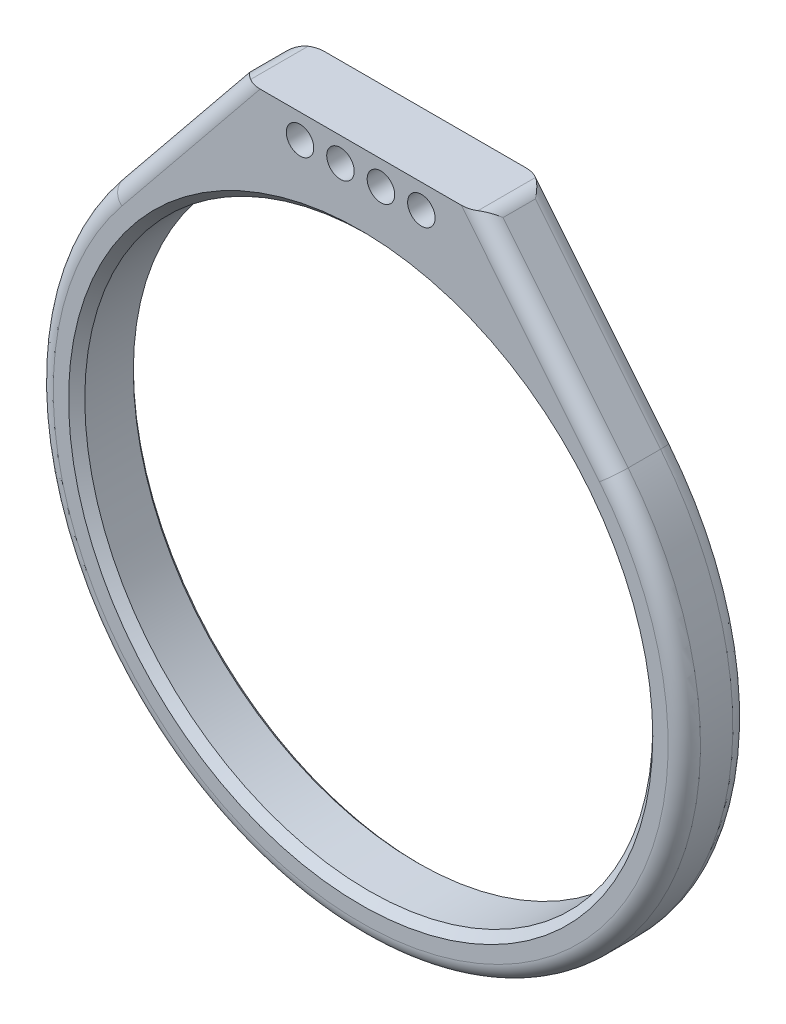
from build123d import *

# Parameters (mm, degrees)
SKETCH1_R                = 35.1
BOSS_EXTRUDE1_DEPTH      = 8
M3_CLEARANCE_HOLE1_D     = 3.4
M3_CLEARANCE_HOLE1_DEPTH = 8
M3_CLEARANCE_HOLE1_TIP   = 1.021463052
CHAMFER1_SIZE            = 1
FILLET1_R                = 2


with BuildPart() as part:
    # Sketch1 → Boss-Extrude1 (new body)
    with BuildSketch(Plane.XY):
        with BuildLine():
            Line((-15, 45), (0, 45))
            Line((0, 45), (15, 45))
            Line((15, 45), (31.062744721, 25.201307315))
            ThreePointArc((31.062744721, 25.201307315), (0, -40), (-31.062744721, 25.201307315))
            Line((-31.062744721, 25.201307315), (-15, 45))
        make_face()
        Circle(SKETCH1_R, mode=Mode.SUBTRACT)
    extrude(amount=BOSS_EXTRUDE1_DEPTH)

    # M3 Clearance Hole1
    with Locations(Plane.XY.offset(8)):
        with Locations((7.5, 42), (-2.5, 42), (-7.5, 42), (2.5, 42)):
            Hole(M3_CLEARANCE_HOLE1_D / 2, depth=M3_CLEARANCE_HOLE1_DEPTH)
            with Locations((0, 0, -(M3_CLEARANCE_HOLE1_DEPTH + M3_CLEARANCE_HOLE1_TIP / 2))):  # 118° drill point
                Cone(0, M3_CLEARANCE_HOLE1_D / 2, M3_CLEARANCE_HOLE1_TIP, mode=Mode.SUBTRACT)

    # Chamfer1
    chamfer1_edges = [part.edges().sort_by_distance(p)[0] for p in [
        (-35.1, 0, 0),
        (-35.1, 0, 8),
    ]]
    chamfer(chamfer1_edges, length=CHAMFER1_SIZE)

    # Fillet1
    fillet1_edges = [part.edges().sort_by_distance(p)[0] for p in [
        (23.031372361, 35.100653658, 8),
        (-36.1, 0, 0),
        (-23.031372361, 35.100653658, 8),
        (23.031372361, 35.100653658, 0),
        (0, -40, 0),
        (-23.031372361, 35.100653658, 0),
        (0, -40, 8),
        (-15, 45, 4),
        (15, 45, 4),
    ]]
    fillet(fillet1_edges, radius=FILLET1_R)


solid = part.part
